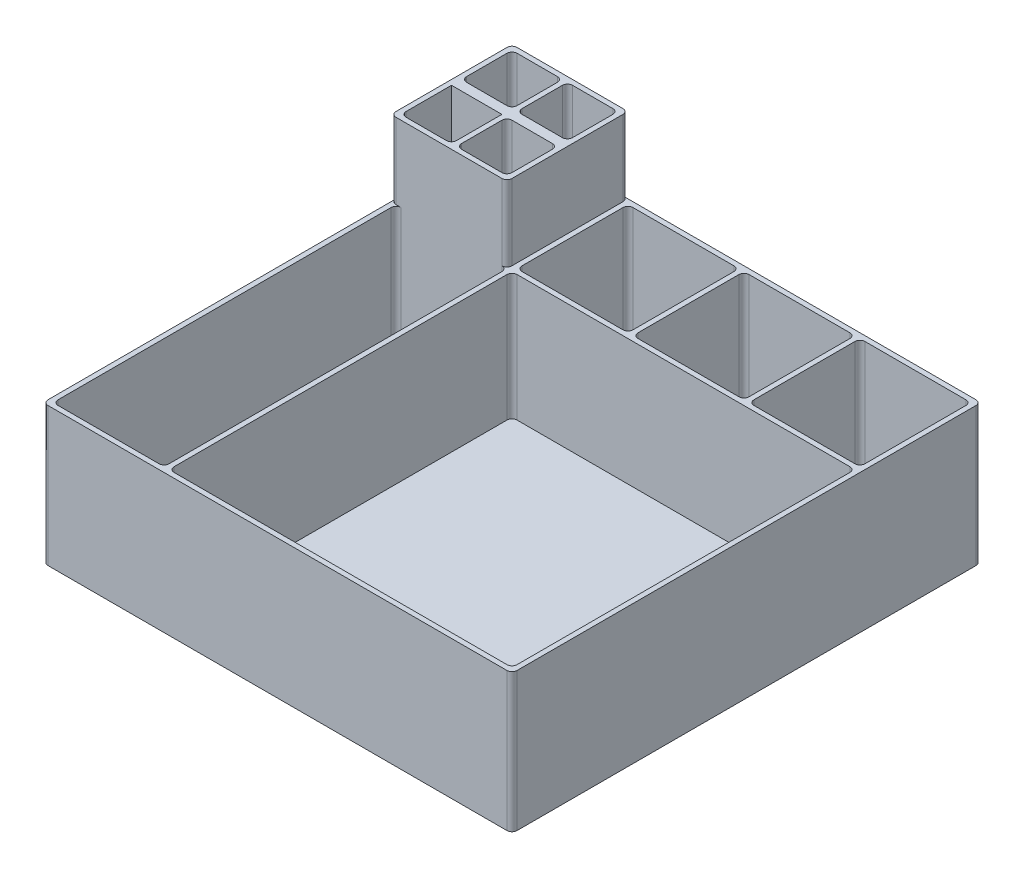
from build123d import *

# Parameters (mm, degrees)
SKETCH1_W                   = 186
SKETCH1_H                   = 186
BOSS_EXTRUDE1_DEPTH         = 5
SKETCH2_W                   = 23
SKETCH2_H                   = 24
SKETCH2_W_2                 = 20
SKETCH2_H_2                 = 20
BOSS_EXTRUDE2_DEPTH         = 80
LPATTERN1_COUNT             = 2
LPATTERN1_PITCH             = 22
MIRROR1_COPY_1_SKETCH_W     = 23
MIRROR1_COPY_1_SKETCH_H     = 24
MIRROR1_COPY_1_SKETCH_W_2   = 20
MIRROR1_COPY_1_SKETCH_H_2   = 20
MIRROR1_COPY_1_DEPTH        = 80
SKETCH3_W                   = 1
SKETCH3_H                   = 48
BOSS_EXTRUDE3_DEPTH         = 80
SKETCH4_W                   = 48
SKETCH4_H                   = 48
SKETCH4_W_2                 = 44
SKETCH4_H_2                 = 44
BOSS_EXTRUDE4_DEPTH         = 50
LPATTERN2_COUNT             = 3
LPATTERN2_PITCH             = 46
LPATTERN3_COUNT             = 4
LPATTERN3_PITCH             = 46
LPATTERN3_COPY_1_SKETCH_W   = 48
LPATTERN3_COPY_1_SKETCH_H   = 48
LPATTERN3_COPY_1_SKETCH_W_2 = 44
LPATTERN3_COPY_1_SKETCH_H_2 = 44
LPATTERN3_COPY_1_DEPTH      = 50
LPATTERN3_COPY_2_SKETCH_W   = 48
LPATTERN3_COPY_2_SKETCH_H   = 48
LPATTERN3_COPY_2_SKETCH_W_2 = 44
LPATTERN3_COPY_2_SKETCH_H_2 = 44
LPATTERN3_COPY_2_DEPTH      = 50
LPATTERN3_COPY_3_SKETCH_W   = 48
LPATTERN3_COPY_3_SKETCH_H   = 48
LPATTERN3_COPY_3_SKETCH_W_2 = 44
LPATTERN3_COPY_3_SKETCH_H_2 = 44
LPATTERN3_COPY_3_DEPTH      = 50
LPATTERN3_COPY_4_SKETCH_W   = 48
LPATTERN3_COPY_4_SKETCH_H   = 48
LPATTERN3_COPY_4_SKETCH_W_2 = 44
LPATTERN3_COPY_4_SKETCH_H_2 = 44
LPATTERN3_COPY_4_DEPTH      = 50
LPATTERN3_COPY_5_SKETCH_W   = 48
LPATTERN3_COPY_5_SKETCH_H   = 48
LPATTERN3_COPY_5_SKETCH_W_2 = 44
LPATTERN3_COPY_5_SKETCH_H_2 = 44
LPATTERN3_COPY_5_DEPTH      = 50
LPATTERN3_COPY_6_SKETCH_W   = 48
LPATTERN3_COPY_6_SKETCH_H   = 48
LPATTERN3_COPY_6_SKETCH_W_2 = 44
LPATTERN3_COPY_6_SKETCH_H_2 = 44
LPATTERN3_COPY_6_DEPTH      = 50
BOSS_EXTRUDE6_DEPTH         = 50
SKETCH9_W                   = 136
SKETCH9_H                   = 136
CUT_EXTRUDE2_DEPTH          = 50
FILLET1_R                   = 2
FILLET2_R                   = 2


with BuildPart() as part:
    # Sketch1 → Boss-Extrude1 (new body)
    with BuildSketch(Plane(origin=(0, 0, 0), x_dir=(1, 0, 0), z_dir=(0, 1, 0))):
        Rectangle(SKETCH1_W, SKETCH1_H)
    extrude(amount=BOSS_EXTRUDE1_DEPTH)

    # Sketch2 → Boss-Extrude2 (add)
    with BuildSketch(Plane(origin=(0, 5, 0), x_dir=(1, 0, 0), z_dir=(0, 1, 0))):
        with Locations((-81.5, 81)):
            Rectangle(SKETCH2_W, SKETCH2_H)
        with Locations((-81, 81)):
            Rectangle(SKETCH2_W_2, SKETCH2_H_2, mode=Mode.SUBTRACT)
    boss_extrude2 = extrude(amount=BOSS_EXTRUDE2_DEPTH)

    # LPattern1: Boss-Extrude2 ×2
    with Locations(*[(i * LPATTERN1_PITCH, 0, 0) for i in range(1, LPATTERN1_COUNT)]):
        add(boss_extrude2)

    # Mirror1: Boss-Extrude2 across plane
    add(boss_extrude2.mirror(Plane(origin=(-93, 85, -69), x_dir=(1, 0, 0), z_dir=(0, 0, -1))))

    # Mirror1 copy 1 sketch → Mirror1 copy 1 (add)
    with BuildSketch(Plane(origin=(22, 5, -138), x_dir=(1, 0, 0), z_dir=(0, 1, 0))):
        with Locations((-81.5, -81)):
            Rectangle(MIRROR1_COPY_1_SKETCH_W, MIRROR1_COPY_1_SKETCH_H)
        with Locations((-81, -81)):
            Rectangle(MIRROR1_COPY_1_SKETCH_W_2, MIRROR1_COPY_1_SKETCH_H_2, mode=Mode.SUBTRACT)
    extrude(amount=MIRROR1_COPY_1_DEPTH)

    # Sketch3 → Boss-Extrude3 (add)
    with BuildSketch(Plane(origin=(0, 5, 0), x_dir=(1, 0, 0), z_dir=(0, 1, 0))):
        with Locations((-47.5, 69)):
            Rectangle(SKETCH3_W, SKETCH3_H)
    extrude(amount=BOSS_EXTRUDE3_DEPTH)

    # Sketch4 → Boss-Extrude4 (add)
    with BuildSketch(Plane(origin=(0, 5, 0), x_dir=(1, 0, 0), z_dir=(0, 1, 0))):
        with Locations((-23, 69)):
            Rectangle(SKETCH4_W, SKETCH4_H)
        with Locations((-23, 69)):
            Rectangle(SKETCH4_W_2, SKETCH4_H_2, mode=Mode.SUBTRACT)
    boss_extrude4 = extrude(amount=BOSS_EXTRUDE4_DEPTH)

    # LPattern2: Boss-Extrude4 ×3
    with Locations(*[(i * LPATTERN2_PITCH, 0, 0) for i in range(1, LPATTERN2_COUNT)]):
        add(boss_extrude4)

    # LPattern3: Boss-Extrude4 ×4
    with Locations(*[(0, 0, i * LPATTERN3_PITCH) for i in range(1, LPATTERN3_COUNT)]):
        add(boss_extrude4)

    # LPattern3 copy 1 sketch → LPattern3 copy 1 (add)
    with BuildSketch(Plane(origin=(46, 5, 46), x_dir=(1, 0, 0), z_dir=(0, 1, 0))):
        with Locations((-23, 69)):
            Rectangle(LPATTERN3_COPY_1_SKETCH_W, LPATTERN3_COPY_1_SKETCH_H)
        with Locations((-23, 69)):
            Rectangle(LPATTERN3_COPY_1_SKETCH_W_2, LPATTERN3_COPY_1_SKETCH_H_2, mode=Mode.SUBTRACT)
    extrude(amount=LPATTERN3_COPY_1_DEPTH)

    # LPattern3 copy 2 sketch → LPattern3 copy 2 (add)
    with BuildSketch(Plane(origin=(46, 5, 92), x_dir=(1, 0, 0), z_dir=(0, 1, 0))):
        with Locations((-23, 69)):
            Rectangle(LPATTERN3_COPY_2_SKETCH_W, LPATTERN3_COPY_2_SKETCH_H)
        with Locations((-23, 69)):
            Rectangle(LPATTERN3_COPY_2_SKETCH_W_2, LPATTERN3_COPY_2_SKETCH_H_2, mode=Mode.SUBTRACT)
    extrude(amount=LPATTERN3_COPY_2_DEPTH)

    # LPattern3 copy 3 sketch → LPattern3 copy 3 (add)
    with BuildSketch(Plane(origin=(46, 5, 138), x_dir=(1, 0, 0), z_dir=(0, 1, 0))):
        with Locations((-23, 69)):
            Rectangle(LPATTERN3_COPY_3_SKETCH_W, LPATTERN3_COPY_3_SKETCH_H)
        with Locations((-23, 69)):
            Rectangle(LPATTERN3_COPY_3_SKETCH_W_2, LPATTERN3_COPY_3_SKETCH_H_2, mode=Mode.SUBTRACT)
    extrude(amount=LPATTERN3_COPY_3_DEPTH)

    # LPattern3 copy 4 sketch → LPattern3 copy 4 (add)
    with BuildSketch(Plane(origin=(92, 5, 46), x_dir=(1, 0, 0), z_dir=(0, 1, 0))):
        with Locations((-23, 69)):
            Rectangle(LPATTERN3_COPY_4_SKETCH_W, LPATTERN3_COPY_4_SKETCH_H)
        with Locations((-23, 69)):
            Rectangle(LPATTERN3_COPY_4_SKETCH_W_2, LPATTERN3_COPY_4_SKETCH_H_2, mode=Mode.SUBTRACT)
    extrude(amount=LPATTERN3_COPY_4_DEPTH)

    # LPattern3 copy 5 sketch → LPattern3 copy 5 (add)
    with BuildSketch(Plane(origin=(92, 5, 92), x_dir=(1, 0, 0), z_dir=(0, 1, 0))):
        with Locations((-23, 69)):
            Rectangle(LPATTERN3_COPY_5_SKETCH_W, LPATTERN3_COPY_5_SKETCH_H)
        with Locations((-23, 69)):
            Rectangle(LPATTERN3_COPY_5_SKETCH_W_2, LPATTERN3_COPY_5_SKETCH_H_2, mode=Mode.SUBTRACT)
    extrude(amount=LPATTERN3_COPY_5_DEPTH)

    # LPattern3 copy 6 sketch → LPattern3 copy 6 (add)
    with BuildSketch(Plane(origin=(92, 5, 138), x_dir=(1, 0, 0), z_dir=(0, 1, 0))):
        with Locations((-23, 69)):
            Rectangle(LPATTERN3_COPY_6_SKETCH_W, LPATTERN3_COPY_6_SKETCH_H)
        with Locations((-23, 69)):
            Rectangle(LPATTERN3_COPY_6_SKETCH_W_2, LPATTERN3_COPY_6_SKETCH_H_2, mode=Mode.SUBTRACT)
    extrude(amount=LPATTERN3_COPY_6_DEPTH)

    # Sketch6 → Boss-Extrude6 (add)
    with BuildSketch(Plane(origin=(0, 5, 0), x_dir=(1, 0, 0), z_dir=(0, 1, 0))):
        Polygon((-47, -93), (-47, -91), (-91, -91), (-91, 45), (-93, 45), (-93, -93), align=None)
    extrude(amount=BOSS_EXTRUDE6_DEPTH)

    # Sketch9 → Cut-Extrude2 (cut)
    with BuildSketch(Plane(origin=(0, 5, 0), x_dir=(1, 0, 0), z_dir=(0, 1, 0))):
        with Locations((23, -23)):
            Rectangle(SKETCH9_W, SKETCH9_H)
    extrude(amount=CUT_EXTRUDE2_DEPTH, mode=Mode.SUBTRACT)

    # Fillet1
    fillet1_edges = [part.edges().sort_by_distance(p)[0] for p in [
        (-69, 45, -47),
        (-49, 45, -47),
        (-49, 45, -67),
        (-69, 45, -67),
        (-47, 70, -93),
        (-45, 30, -91),
        (-45, 30, -47),
        (-1, 30, -47),
        (-1, 30, -91),
        (47, 30, -47),
        (1, 30, -91),
        (1, 30, -47),
        (45, 30, -47),
        (45, 30, -91),
        (47, 30, -91),
        (91, 30, -47),
        (91, 30, -91),
        (-91, 45, -71),
        (-71, 45, -71),
        (-71, 45, -91),
        (-91, 45, -91),
        (-47, 30, -45),
        (-45, 30, -45),
        (-45, 30, 91),
        (91, 30, -45),
        (91, 30, 91),
        (-47, 30, 91),
        (-91, 30, 91),
        (-91, 30, -45),
        (-69, 45, -71),
        (-49, 45, -71),
        (-49, 45, -91),
        (-69, 45, -91),
        (-93, 42.5, -93),
        (93, 27.5, -93),
        (93, 27.5, 93),
        (-93, 27.5, 93),
        (-91, 45, -47),
        (-71, 45, -47),
    ]]
    fillet(fillet1_edges, radius=FILLET1_R)

    # Fillet2
    fillet2_edges = [part.edges().sort_by_distance(p)[0] for p in [
        (-47, 70, -45),
        (-93, 70, -45),
    ]]
    fillet(fillet2_edges, radius=FILLET2_R)


solid = part.part
